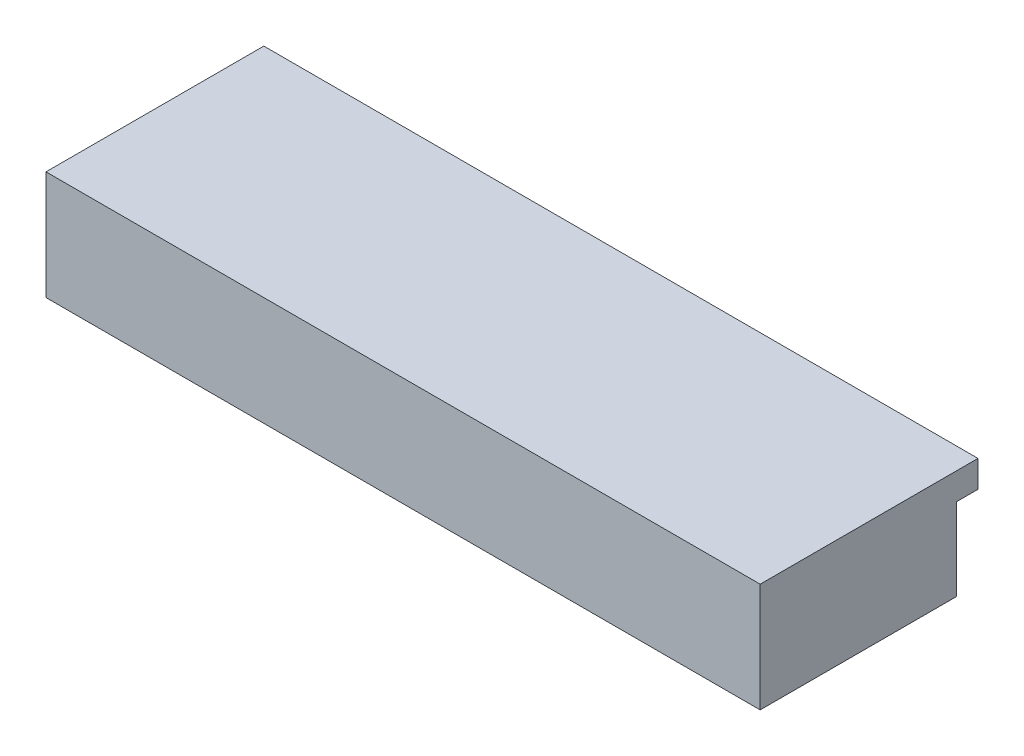
from build123d import *

# Parameters (mm, degrees)
ESQUISSE3_W      = 400
ESQUISSE3_H      = 40
EXTRUSION1_DEPTH = 110
ESQUISSE8_W      = 400
ESQUISSE8_H      = 122
EXTRUSION3_DEPTH = 15
ESQUISSE11_W     = 400
ESQUISSE11_H     = 110
EXTRUSION5_DEPTH = 6
ESQUISSE10_R     = 1
EXTRUSION4_DEPTH = 1.5
ESQUISSE12_R     = 1
EXTRUSION6_DEPTH = 20


with BuildPart() as part:
    # Esquisse3 → Extrusion1 (new body)
    with BuildSketch(Plane.XY):
        with Locations((38, 5)):
            Rectangle(ESQUISSE3_W, ESQUISSE3_H)
    extrude(amount=EXTRUSION1_DEPTH)

    # Esquisse8 → Extrusion3 (add)
    with BuildSketch(Plane(origin=(0, 25, 0), x_dir=(1, 0, 0), z_dir=(0, 1, 0))):
        with Locations((38, -49)):
            Rectangle(ESQUISSE8_W, ESQUISSE8_H)
    extrude(amount=EXTRUSION3_DEPTH)

    # Esquisse11 → Extrusion5 (add)
    with BuildSketch(Plane.XZ.offset(15)):
        with Locations((38, 55)):
            Rectangle(ESQUISSE11_W, ESQUISSE11_H)
    extrude(amount=EXTRUSION5_DEPTH)

    # Esquisse10 → Extrusion4 (cut)
    with BuildSketch(Plane(origin=(0, 0, 0), x_dir=(-1, 0, 0), z_dir=(0, 0, -1))):
        with BuildLine():
            Line((59.5, -8), (59.5, -19))
            ThreePointArc((59.5, -19), (58.914213562, -20.414213562), (57.5, -21))
            Line((57.5, -21), (-68.5, -21))
            ThreePointArc((-68.5, -21), (-69.914213562, -20.414213562), (-70.5, -19))
            Line((-70.5, -19), (-70.5, -8))
            ThreePointArc((-70.5, -8), (-71.085786438, -6.585786438), (-72.5, -6))
            Line((-72.5, -6), (-83, -6))
            ThreePointArc((-83, -6), (-95.5, 6.5), (-83, 19))
            Line((-83, 19), (70.25, 19))
            ThreePointArc((70.25, 19), (82.75, 6.5), (70.25, -6))
            Line((70.25, -6), (61.5, -6))
            ThreePointArc((61.5, -6), (60.085786438, -6.585786438), (59.5, -8))
        make_face()
        with Locations((-86.5, 6.5)):
            Circle(ESQUISSE10_R, mode=Mode.SUBTRACT)
        with Locations((-20.5, 6.5)):
            Circle(ESQUISSE10_R, mode=Mode.SUBTRACT)
        with Locations((72.75, 6.5)):
            Circle(ESQUISSE10_R, mode=Mode.SUBTRACT)
        with BuildLine():
            Line((-31.5, -3), (-61.5, -3))
            ThreePointArc((-61.5, -3), (-62.207106781, -2.707106781), (-62.5, -2))
            Line((-62.5, -2), (-62.5, 12))
            ThreePointArc((-62.5, 12), (-62.207106781, 12.707106781), (-61.5, 13))
            Line((-61.5, 13), (-31.5, 13))
            ThreePointArc((-31.5, 13), (-30.792893219, 12.707106781), (-30.5, 12))
            Line((-30.5, 12), (-30.5, -2))
            ThreePointArc((-30.5, -2), (-30.792893219, -2.707106781), (-31.5, -3))
        make_face(mode=Mode.SUBTRACT)
        with BuildLine():
            Line((51.75, 0), (12.75, 0))
            ThreePointArc((12.75, 0), (12.042893219, 0.292893219), (11.75, 1))
            Line((11.75, 1), (11.75, 11))
            ThreePointArc((11.75, 11), (12.042893219, 11.707106781), (12.75, 12))
            Line((12.75, 12), (51.75, 12))
            ThreePointArc((51.75, 12), (52.457106781, 11.707106781), (52.75, 11))
            Line((52.75, 11), (52.75, 1))
            ThreePointArc((52.75, 1), (52.457106781, 0.292893219), (51.75, 0))
        make_face(mode=Mode.SUBTRACT)
    extrude(amount=-EXTRUSION4_DEPTH, mode=Mode.SUBTRACT)

    # Esquisse12 → Extrusion6 (cut)
    with BuildSketch(Plane(origin=(0, 0, 0), x_dir=(-1, 0, 0), z_dir=(0, 0, -1))):
        with Locations((-86.5, 6.5)):
            Circle(ESQUISSE12_R)
        with Locations((-20.5, 6.5)):
            Circle(ESQUISSE12_R)
        with Locations((72.75, 6.5)):
            Circle(ESQUISSE12_R)
        with BuildLine():
            Line((-30.5, -2), (-30.5, 12))
            ThreePointArc((-30.5, 12), (-30.792893219, 12.707106781), (-31.5, 13))
            Line((-31.5, 13), (-61.5, 13))
            ThreePointArc((-61.5, 13), (-62.207106781, 12.707106781), (-62.5, 12))
            Line((-62.5, 12), (-62.5, -2))
            ThreePointArc((-62.5, -2), (-62.207106781, -2.707106781), (-61.5, -3))
            Line((-61.5, -3), (-31.5, -3))
            ThreePointArc((-31.5, -3), (-30.792893219, -2.707106781), (-30.5, -2))
        make_face()
        with BuildLine():
            Line((52.75, 1), (52.75, 11))
            ThreePointArc((52.75, 11), (52.457106781, 11.707106781), (51.75, 12))
            Line((51.75, 12), (12.75, 12))
            ThreePointArc((12.75, 12), (12.042893219, 11.707106781), (11.75, 11))
            Line((11.75, 11), (11.75, 1))
            ThreePointArc((11.75, 1), (12.042893219, 0.292893219), (12.75, 0))
            Line((12.75, 0), (51.75, 0))
            ThreePointArc((51.75, 0), (52.457106781, 0.292893219), (52.75, 1))
        make_face()
    extrude(amount=-EXTRUSION6_DEPTH, mode=Mode.SUBTRACT)


solid = part.part
